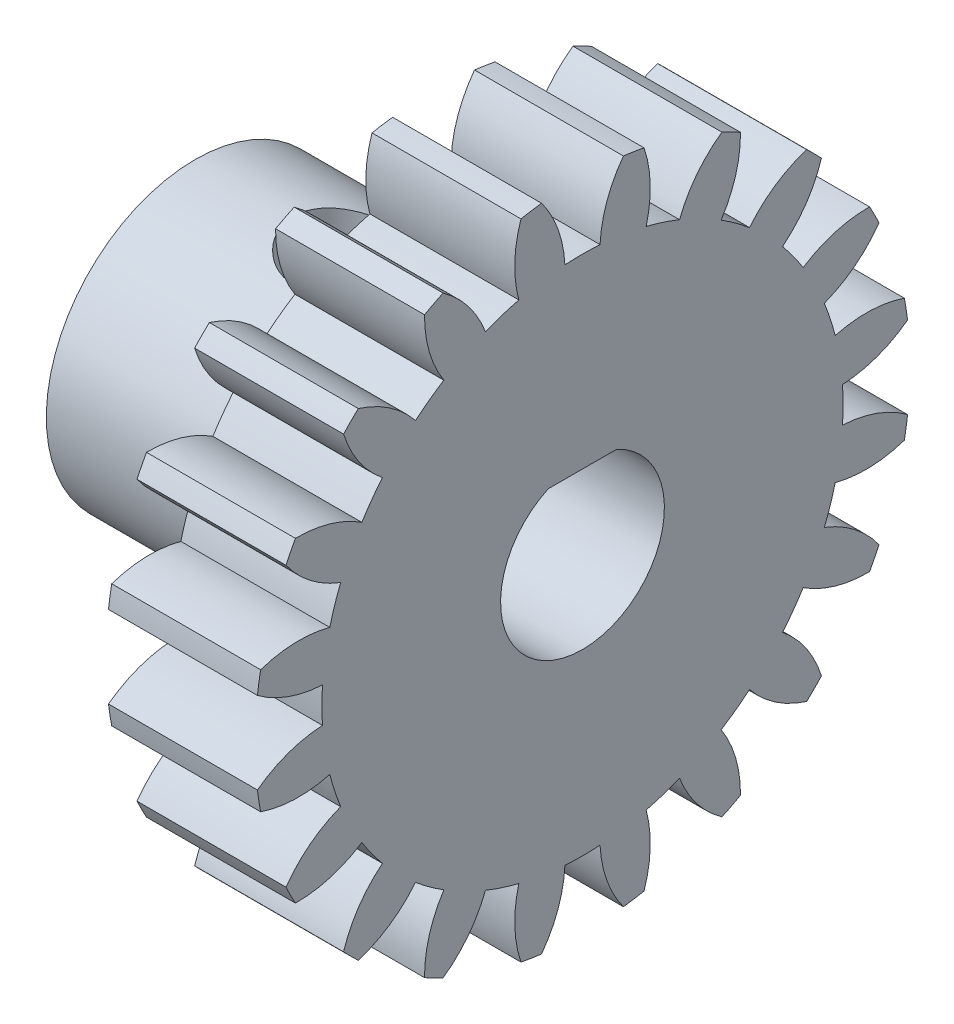
from build123d import *

# Parameters (mm, degrees)
BASPROSKE_W             = 5
BASPROSKE_H             = 11
TOOTHCUT_DEPTH          = 17.340134638
TEETHCUTS_COUNT         = 20
TEETHCUTS_ANGLE         = 342
HUBNEAONESKE_R          = 5
HUBNEARONE_DEPTH        = 10.0000508
BORSKE_R                = 3
BORE_DEPTH              = 15.0000508
BOSS_EXTRUDE1_START     = -10.000051
SKETCH2_R               = 3
BOSS_EXTRUDE1_DEPTH     = 15.0000508
SKETCH3_R               = 1.7
CUT_EXTRUDE1_DEPTH      = 10
SKETCH4_W               = 2
SKETCH4_H               = 20.201666504
CUT_EXTRUDE2_DEPTH      = 19.39087628
CUT_EXTRUDE2_DEPTH_BACK = 19.39087628
CUT_EXTRUDE3_DEPTH      = 31


with BuildPart() as part:
    # BasProSke → Base-Revolve (revolve)
    with BuildSketch(Plane(origin=(0, 0, 0), x_dir=(1, 0, 0), z_dir=(0, 1, 0)), mode=Mode.PRIVATE) as base_revolve_sk:
        with Locations((2.5, 5.5)):
            Rectangle(BASPROSKE_W, BASPROSKE_H)
    revolve(base_revolve_sk.sketch.rotate(Axis((-10, 0, 0), (1, 0, 0)), 180), axis=Axis((-10, 0, 0), (1, 0, 0)))

    # TooCutSke → ToothCut (cut, through all)
    with BuildSketch(Plane(origin=(0, 0, 0), x_dir=(0, 0, -1), z_dir=(1, 0, 0))):
        with BuildLine():
            ThreePointArc((0.589353609, 8.729127295), (0, 8.749), (-0.589353609, 8.729127295))
            ThreePointArc((-0.589353609, 8.729127295), (-0.82475631, 9.893403384), (-1.391689312, 10.937213814))
            ThreePointArc((-1.391689312, 10.937213814), (0, 11.0254), (1.391689312, 10.937213814))
            ThreePointArc((1.391689312, 10.937213814), (0.82475631, 9.893403384), (0.589353609, 8.729127295))
        make_face()
    toothcut = extrude(amount=TOOTHCUT_DEPTH, mode=Mode.SUBTRACT)

    # TeethCuts: ToothCut ×20 about axis
    teethcuts_axis = Axis((-10, 0, 0), (1, 0, 0))
    for i in range(1, TEETHCUTS_COUNT):
        add(toothcut.rotate(teethcuts_axis, i * TEETHCUTS_ANGLE / (TEETHCUTS_COUNT - 1)), mode=Mode.SUBTRACT)

    # HubNeaOneSke → HubNearOne (add)
    with BuildSketch(Plane.ZY):
        with Locations(Location((0, 0, 0), (0, 0, 180))):
            Circle(HUBNEAONESKE_R)
    extrude(amount=HUBNEARONE_DEPTH)

    # BorSke → Bore (cut, symmetric)
    with BuildSketch(Plane(origin=(0, 0, 0), x_dir=(0, 0, -1), z_dir=(1, 0, 0))):
        with Locations(Location((0, 0, 0), (0, 0, 180))):
            Circle(BORSKE_R)
    extrude(amount=BORE_DEPTH, both=True, mode=Mode.SUBTRACT)

    # Sketch2 → Boss-Extrude1 (add)
    with BuildSketch(Plane(origin=(0, 0, 0), x_dir=(0, 0, -1), z_dir=(1, 0, 0)).offset(BOSS_EXTRUDE1_START)):
        Circle(SKETCH2_R)
        with BuildLine():
            Line((-1.65, 2.2), (1.65, 2.2))
            ThreePointArc((1.65, 2.2), (0, -2.75), (-1.65, 2.2))
        make_face(mode=Mode.SUBTRACT)
    extrude(amount=BOSS_EXTRUDE1_DEPTH)

    # Sketch3 → Cut-Extrude1 (cut)
    with BuildSketch(Plane(origin=(0, 0, 0), x_dir=(1, 0, 0), z_dir=(0, 1, 0))):
        with Locations(Location((-3.0000508, 0, 0), (0, 0, 90))):
            Circle(SKETCH3_R)
    extrude(amount=CUT_EXTRUDE1_DEPTH, mode=Mode.SUBTRACT)

    # Sketch4 → Cut-Extrude2 (cut, two sides)
    with BuildSketch(Plane.XY) as cut_extrude2_sk:
        with Locations((-9.0000508, 0)):
            Rectangle(SKETCH4_W, SKETCH4_H)
    extrude(amount=CUT_EXTRUDE2_DEPTH, mode=Mode.SUBTRACT)
    extrude(cut_extrude2_sk.sketch, amount=-CUT_EXTRUDE2_DEPTH_BACK, mode=Mode.SUBTRACT)

    # Sketch5 → Cut-Extrude3 (cut)
    with BuildSketch(Plane.ZY.offset(8.0000508)):
        with BuildLine():
            Line((1.145643924, 2.5), (0, 2.5))
            Line((0, 2.5), (-1.145643924, 2.5))
            ThreePointArc((-1.145643924, 2.5), (-1.40584716, 2.363491858), (-1.65, 2.2))
            Line((-1.65, 2.2), (1.65, 2.2))
            ThreePointArc((1.65, 2.2), (1.40584716, 2.363491858), (1.145643924, 2.5))
        make_face()
    extrude(amount=-CUT_EXTRUDE3_DEPTH, mode=Mode.SUBTRACT)


solid = part.part
